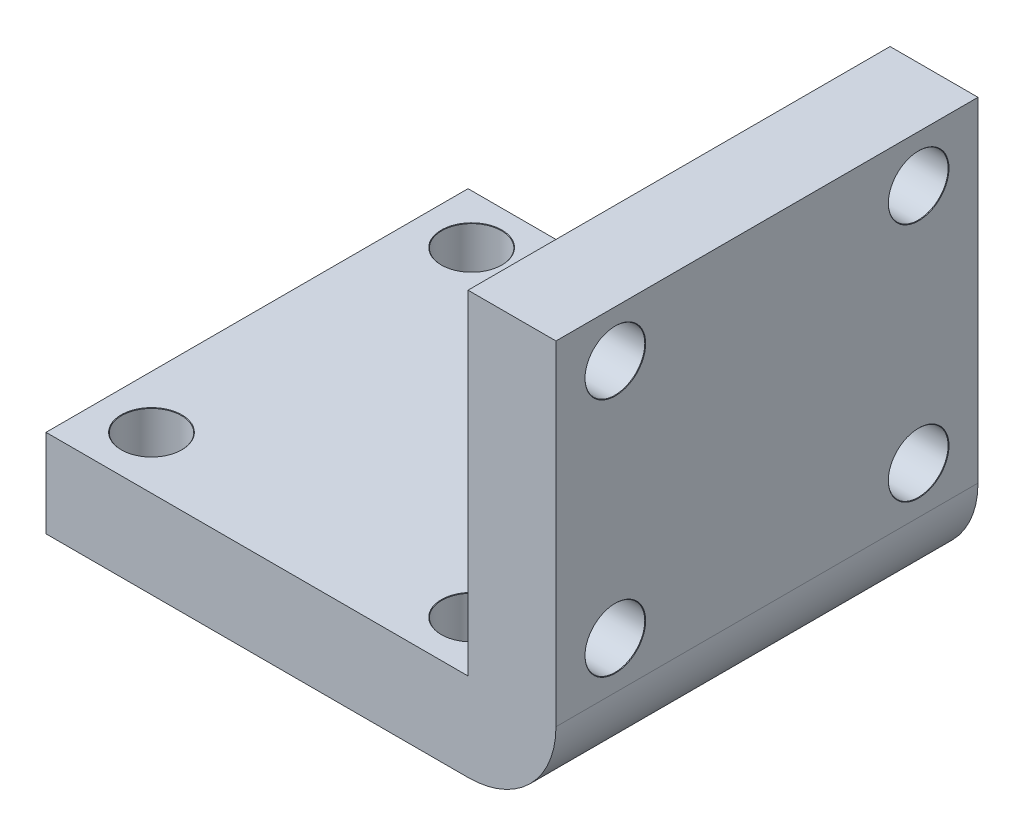
from build123d import *

# Parameters (mm, degrees)
SKETCH1_W                      = 24
SKETCH1_H                      = 24
BOSS_EXTRUDE1_DEPTH            = 5
BOSS_EXTRUDE2_START            = 12
SKETCH2_W                      = 24
SKETCH2_H                      = 24
BOSS_EXTRUDE2_DEPTH            = 5
FILLET3_R                      = 5
M3_CLEARANCE_HOLE1_D           = 3.4
M3_CLEARANCE_HOLE1_CSINK_D     = 3.45
M3_CLEARANCE_HOLE1_CSINK_ANGLE = 90
M3_CLEARANCE_HOLE2_D           = 3.4
M3_CLEARANCE_HOLE2_CSINK_D     = 3.45
M3_CLEARANCE_HOLE2_CSINK_ANGLE = 90


with BuildPart() as part:
    # Sketch1 → Boss-Extrude1 (new body)
    with BuildSketch(Plane(origin=(0, 0, 0), x_dir=(1, 0, 0), z_dir=(0, 1, 0))):
        Rectangle(SKETCH1_W, SKETCH1_H)
    extrude(amount=BOSS_EXTRUDE1_DEPTH)

    # Sketch2 → Boss-Extrude2 (add)
    with BuildSketch(Plane(origin=(0, 0, 0), x_dir=(0, 0, -1), z_dir=(1, 0, 0)).offset(BOSS_EXTRUDE2_START)):
        with Locations((0, 12)):
            Rectangle(SKETCH2_W, SKETCH2_H)
    extrude(amount=BOSS_EXTRUDE2_DEPTH)

    # Fillet3
    fillet3_edges = [part.edges().sort_by_distance(p)[0] for p in [
        (17, 0, 0),
    ]]
    fillet(fillet3_edges, radius=FILLET3_R)

    # M3 Clearance Hole1 (through all)
    with Locations(Plane(origin=(17, 0, 0), x_dir=(0, 0, -1), z_dir=(1, 0, 0))):
        with Locations((-8.624504069, 21.327732388), (8.624504069, 21.327732388), (8.624504069, 7.672267612), (-8.624504069, 7.672267612)):
            CounterSinkHole(M3_CLEARANCE_HOLE1_D / 2, M3_CLEARANCE_HOLE1_CSINK_D / 2, counter_sink_angle=M3_CLEARANCE_HOLE1_CSINK_ANGLE)

    # M3 Clearance Hole2 (through all)
    with Locations(Plane(origin=(0, 5, 0), x_dir=(1, 0, 0), z_dir=(0, 1, 0))):
        with Locations((-9, -9), (-9, 9.203654699), (9.203654699, 9.203654699), (9.203654699, -9)):
            CounterSinkHole(M3_CLEARANCE_HOLE2_D / 2, M3_CLEARANCE_HOLE2_CSINK_D / 2, counter_sink_angle=M3_CLEARANCE_HOLE2_CSINK_ANGLE)


solid = part.part
